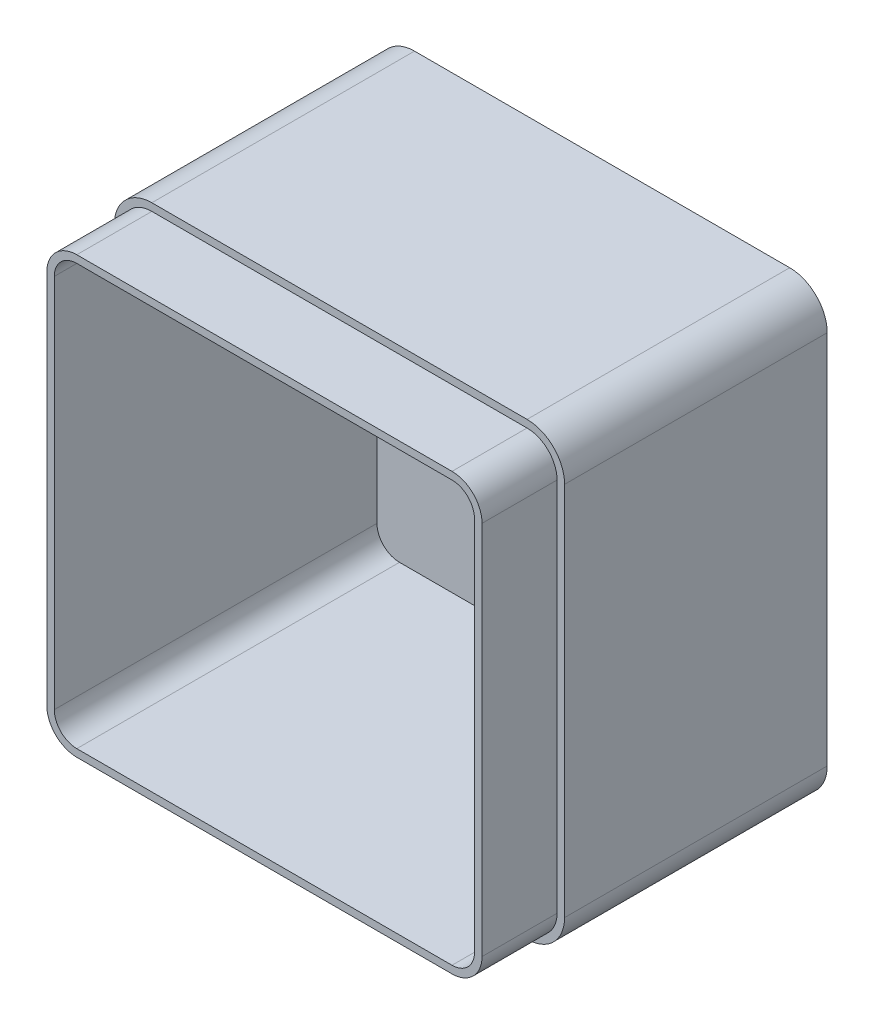
from build123d import *

# Parameters (mm, degrees)
SKETCH2_W               = 120
SKETCH2_H               = 120
BOSS_EXTRUDE1_DEPTH     = 90
FILLET1_R               = 10
SHELL2_T                = -4
CUT_EXTRUDE3_DEPTH      = 20
CUT_EXTRUDE3_DEPTH_BACK = 20


with BuildPart() as part:
    # Sketch2 → Boss-Extrude1 (new body)
    with BuildSketch(Plane.XY):
        with Locations((60, 60)):
            Rectangle(SKETCH2_W, SKETCH2_H)
    extrude(amount=BOSS_EXTRUDE1_DEPTH)

    # Fillet1
    fillet1_edges = [part.edges().sort_by_distance(p)[0] for p in [
        (0, 120, 45),
        (120, 120, 45),
        (120, 0, 45),
        (0, 0, 45),
    ]]
    fillet(fillet1_edges, radius=FILLET1_R)

    # Shell2
    shell2_openings = [part.faces().sort_by_distance(p)[0] for p in [
        (60, 60, 90),
    ]]
    offset(amount=SHELL2_T, openings=shell2_openings, kind=Kind.INTERSECTION)

    # Sketch3 → Cut-Extrude3 (cut, two sides)
    with BuildSketch(Plane.XY.offset(90)) as cut_extrude3_sk:
        with BuildLine():
            Line((10, 0), (110, 0))
            ThreePointArc((110, 0), (117.071067812, 2.928932188), (120, 10))
            Line((120, 10), (120, 110))
            ThreePointArc((120, 110), (117.071067812, 117.071067812), (110, 120))
            Line((110, 120), (10, 120))
            ThreePointArc((10, 120), (2.928932188, 117.071067812), (0, 110))
            Line((0, 110), (0, 10))
            ThreePointArc((0, 10), (2.928932188, 2.928932188), (10, 0))
        make_face()
        with BuildLine():
            Line((10, 2), (110, 2))
            ThreePointArc((110, 2), (115.656854249, 4.343145751), (118, 10))
            Line((118, 10), (118, 110))
            ThreePointArc((118, 110), (115.656854249, 115.656854249), (110, 118))
            Line((110, 118), (10, 118))
            ThreePointArc((10, 118), (4.343145751, 115.656854249), (2, 110))
            Line((2, 110), (2, 10))
            ThreePointArc((2, 10), (4.343145751, 4.343145751), (10, 2))
        make_face(mode=Mode.SUBTRACT)
    extrude(amount=CUT_EXTRUDE3_DEPTH, mode=Mode.SUBTRACT)
    extrude(cut_extrude3_sk.sketch, amount=-CUT_EXTRUDE3_DEPTH_BACK, mode=Mode.SUBTRACT)


solid = part.part
